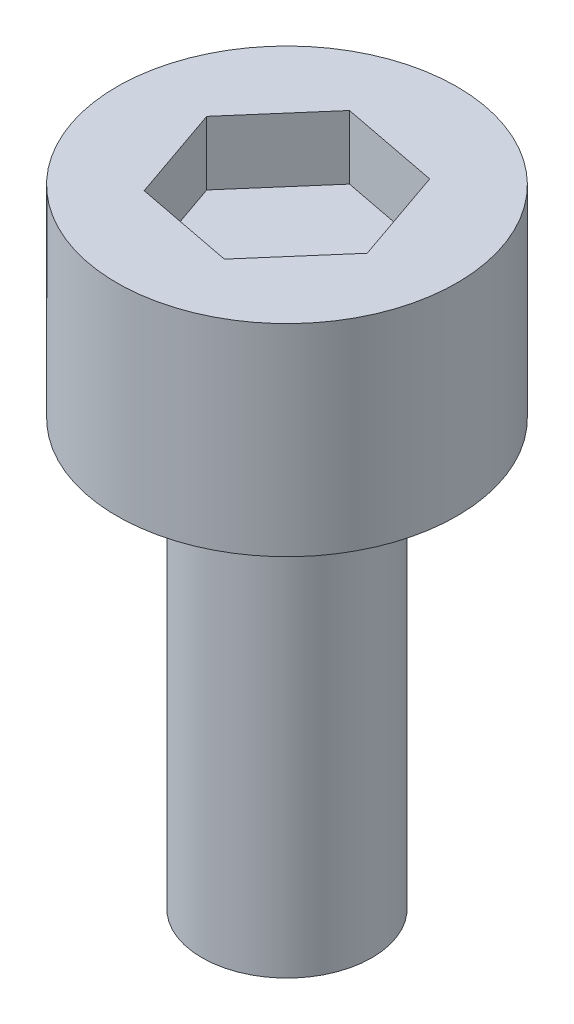
from build123d import *

# Parameters (mm, degrees)
CUT_EXTRUDE1_DEPTH = 3


with BuildPart() as part:
    # Sketch1 → Revolve1 (revolve)
    with BuildSketch(Plane.XY):
        Polygon((0, 0), (4, 0), (4, 20), (8, 20), (8, 29.5), (0, 29.5), align=None)
    revolve(axis=Axis((0, 0, 0), (0, 1, 0)))

    # Sketch2 → Cut-Extrude1 (cut)
    with BuildSketch(Plane(origin=(0, 29.5, 0), x_dir=(1, 0, 0), z_dir=(0, 1, 0))):
        Polygon((3.119102549, 3.598917707), (-1.557202886, 4.500680898), (-4.676305435, 0.901763191), (-3.119102549, -3.598917707), (1.557202886, -4.500680898), (4.676305435, -0.901763191), align=None)
    extrude(amount=-CUT_EXTRUDE1_DEPTH, mode=Mode.SUBTRACT)


solid = part.part
